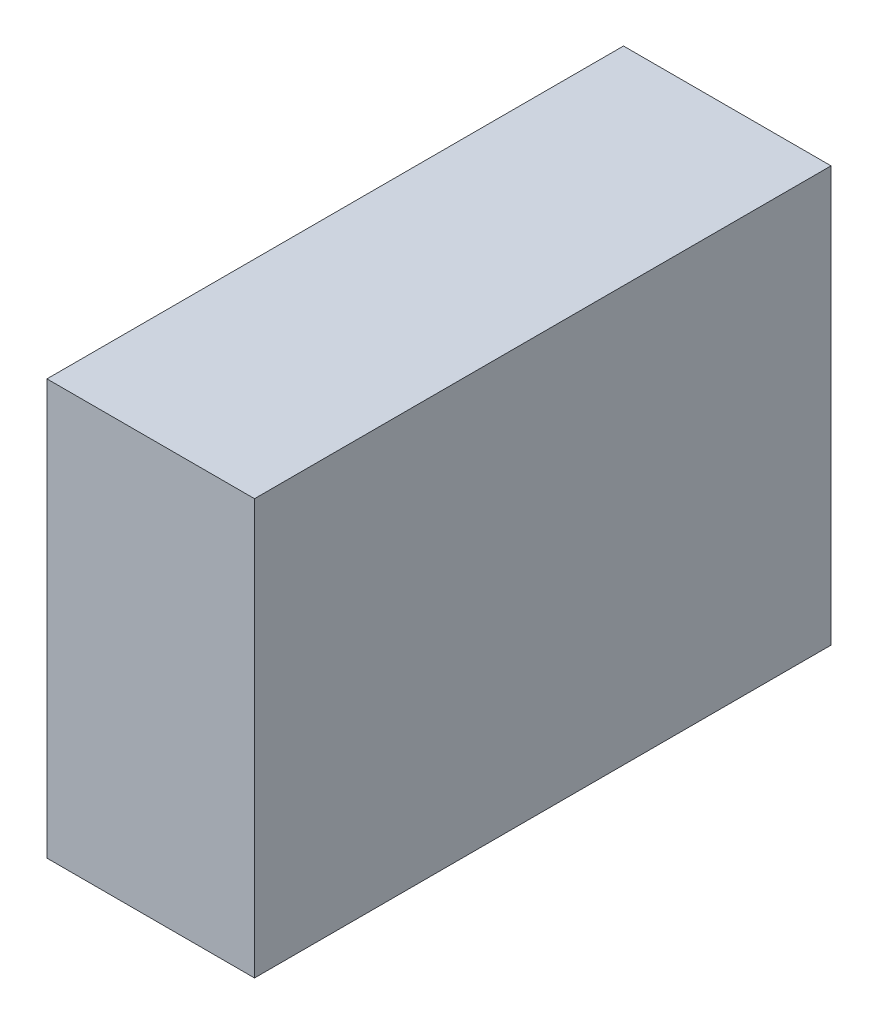
from build123d import *

# Parameters (mm, degrees)
SCHIZZO1_W                   = 18
SCHIZZO1_H                   = 36
ESTRUSIONE_ESTRUSIONE1_DEPTH = 50


with BuildPart() as part:
    # Schizzo1 → Estrusione-Estrusione1 (new body)
    with BuildSketch(Plane.XY):
        with Locations((9, 18)):
            Rectangle(SCHIZZO1_W, SCHIZZO1_H)
    extrude(amount=ESTRUSIONE_ESTRUSIONE1_DEPTH)


solid = part.part
